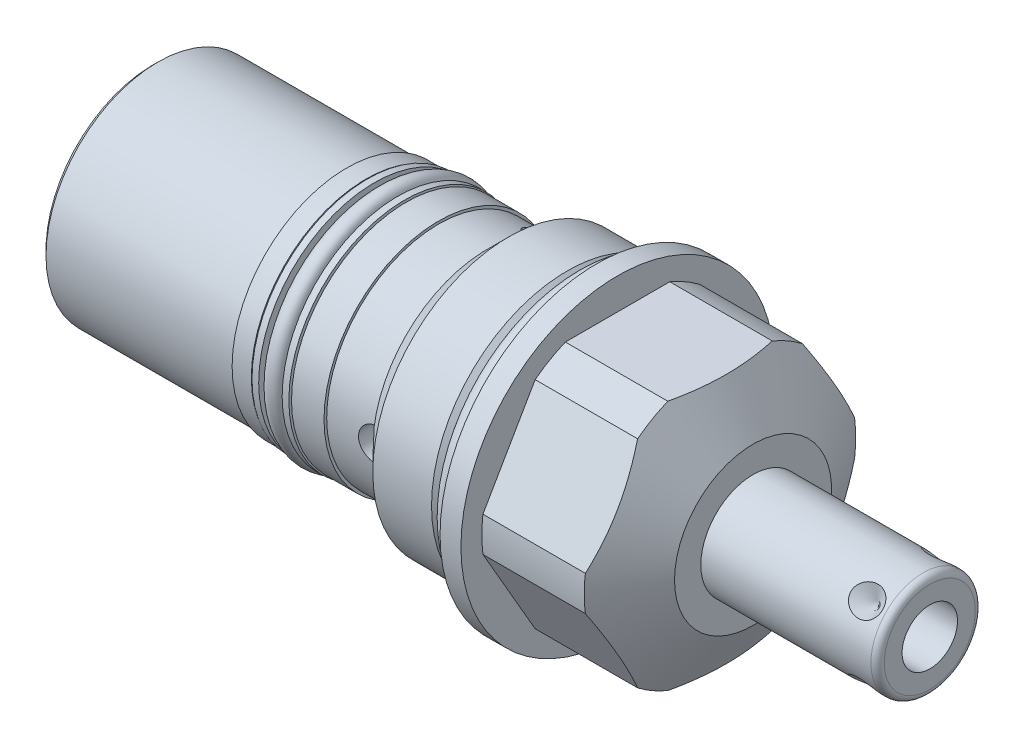
from build123d import *

# Parameters (mm, degrees)
SKETCH1_R           = 23.8125
EXTRUDE1_DEPTH      = 23.7744
EXTRUDE1_DEPTH_BACK = 67.4624
CUT_EXTRUDE1_REACH  = 69.462
SKETCH2_R           = 23.8125
SKETCH2_R_2         = 20.6375
CUT_EXTRUDE3_REACH  = 22.599
SKETCH5_R           = 23.8125
CUT_EXTRUDE5_START  = -15.576741
SKETCH7_R           = 23.8125
SKETCH7_R_2         = 20.6375
CUT_EXTRUDE5_DEPTH  = 15.576741
SKETCH12_W          = 6.1087
SKETCH12_H          = 2.032
SKETCH14_W          = 0.4064
SKETCH14_H          = 29.464
SKETCH14_H_2        = 7.4168
SKETCH15_R          = 1.4986
SKETCH16_W          = 2.1844
SKETCH16_H          = 1.016
SKETCH17_R          = 1.3081
CHAMFER1_SIZE       = 0.762
SKETCH23_R          = 2.5273
CUT_EXTRUDE7_DEPTH  = 24.8125
SKETCH25_R          = 3.1369
CUT_EXTRUDE8_DEPTH  = 0.762
SKETCH26_R          = 13.0302
EXTRUDE2_DEPTH      = 0.508
SKETCH28_R          = 3.1369
CUT_EXTRUDE9_DEPTH  = 0.508
CIRPATTERN2_COUNT   = 3
CIRPATTERN3_COUNT   = 4


with BuildPart() as part:
    # Sketch1 → Extrude1 (new body, two sides)
    with BuildSketch(Plane(origin=(0, 0, 0), x_dir=(0, 0, -1), z_dir=(1, 0, 0))) as extrude1_sk:
        Circle(SKETCH1_R)
    extrude(amount=EXTRUDE1_DEPTH)
    extrude(extrude1_sk.sketch, amount=-EXTRUDE1_DEPTH_BACK)

    # Sketch2 → Cut-Extrude1 (cut, up to next)
    with BuildSketch(Plane(origin=(0, 0, 0), x_dir=(0, 0, -1), z_dir=(1, 0, 0)), mode=Mode.PRIVATE) as cut_extrude1_sk1:
        Circle(SKETCH2_R)
        Circle(SKETCH2_R_2, mode=Mode.SUBTRACT)
    cut_extrude1_tool1 = extrude(cut_extrude1_sk1.sketch, amount=-CUT_EXTRUDE1_REACH, mode=Mode.PRIVATE) & part.part
    add(cut_extrude1_tool1.solids().sort_by_distance((0, 0, 23.138981))[0], mode=Mode.SUBTRACT)

    # Sketch3 → Cut-Revolve1 (revolve, cut)
    with BuildSketch(Plane.XY, mode=Mode.PRIVATE) as cut_revolve1_sk:
        Polygon((16.918654229, 23.8125), (23.7744, 11.938), (23.7744, 23.8125), align=None)
    revolve(cut_revolve1_sk.sketch.rotate(Axis((-8.14577342, 0, 0), (1, 0, 0)), 270), axis=Axis((-8.14577342, 0, 0), (1, 0, 0)), mode=Mode.SUBTRACT)  # turned: the seam where the file's is

    # Cut-Extrude3: up to this cone (the profile starts inside it)
    cut_extrude3_end = Plane(origin=(3.175, 0, 0), z_dir=(-1, 0, 0)).offset(-27.491806514) * Cone(1.732e-06, 170.10127155, 98.208013919, align=(Align.CENTER, Align.CENTER, Align.MIN), mode=Mode.PRIVATE)
    # Sketch5 → Cut-Extrude3 (cut, up to the surface)
    with BuildSketch(Plane.ZY.offset(-3.175), mode=Mode.PRIVATE) as cut_extrude3_sk1:
        with Locations(Location((0, 0, 0), (0, 0, 180))):  # turned: the seam where the file's is
            Circle(SKETCH5_R)
        Polygon((-10.998522628, 19.05), (10.998522628, 19.05), (21.997045256, 0), (10.998522628, -19.05), (-10.998522628, -19.05), (-21.997045256, 0), align=None, mode=Mode.SUBTRACT)
    cut_extrude3_tool1 = extrude(cut_extrude3_sk1.sketch, amount=-CUT_EXTRUDE3_REACH, mode=Mode.PRIVATE) & cut_extrude3_end
    add(cut_extrude3_tool1.solids().sort_by_distance((3.175, 0, 23.138981))[0], mode=Mode.SUBTRACT)

    # Sketch7 → Cut-Extrude5 (cut)
    with BuildSketch(Plane.ZY.offset(-3.175).offset(CUT_EXTRUDE5_START)):
        with Locations(Location((0, 0, 0), (0, 0, 180))):  # turned: the seam where the file's is
            Circle(SKETCH7_R)
        with Locations(Location((0, 0, 0), (0, 0, 180))):  # turned: the seam where the file's is
            Circle(SKETCH7_R_2, mode=Mode.SUBTRACT)
    extrude(amount=CUT_EXTRUDE5_DEPTH, mode=Mode.SUBTRACT)

    # Sketch9 → Cut-Revolve3 (revolve, cut)
    with BuildSketch(Plane.XY, mode=Mode.PRIVATE) as cut_revolve3_sk:
        Polygon((0, 20.6375), (0, 19.1389), (-2.9718, 19.1389), (-4.4704, 20.6375), align=None)
    revolve(cut_revolve3_sk.sketch.rotate(Axis((-4.4205525, 0, 0), (1, 0, 0)), 90), axis=Axis((-4.4205525, 0, 0), (1, 0, 0)), mode=Mode.SUBTRACT)  # turned: the seam where the file's is

    # Sketch10 → Cut-Revolve4 (revolve, cut)
    with BuildSketch(Plane.XY, mode=Mode.PRIVATE) as cut_revolve4_sk:
        Polygon((-13.3985, 20.6375), (-16.6116, 17.4244), (-67.4624, 17.4244), (-67.4624, 20.6375), align=None)
    revolve(cut_revolve4_sk.sketch.rotate(Axis((-55.9469925, 0, 0), (1, 0, 0)), 90), axis=Axis((-55.9469925, 0, 0), (1, 0, 0)), mode=Mode.SUBTRACT)  # turned: the seam where the file's is

    # Sketch12 → Cut-Revolve6 (revolve, cut)
    with BuildSketch(Plane.XY, mode=Mode.PRIVATE) as cut_revolve6_sk:
        with Locations((-32.02305, 16.4084)):
            Rectangle(SKETCH12_W, SKETCH12_H)
    revolve(cut_revolve6_sk.sketch.rotate(Axis((-31.750635, 0, 0), (1, 0, 0)), 90), axis=Axis((-31.750635, 0, 0), (1, 0, 0)), mode=Mode.SUBTRACT)  # turned: the seam where the file's is

    # Sketch14 → Cut-Revolve8 (revolve, cut)
    with BuildSketch(Plane(origin=(0, 0, 0), x_dir=(0, -1, 0), z_dir=(0, 0, 1)), mode=Mode.PRIVATE) as cut_revolve8_sk:
        with Locations((17.2212, -52.7304)):
            Rectangle(SKETCH14_W, SKETCH14_H)
        with Locations((17.2212, -20.32)):
            Rectangle(SKETCH14_W, SKETCH14_H_2)
    revolve(cut_revolve8_sk.sketch.rotate(Axis((-55.86603, 0, 0), (1, 0, 0)), 270), axis=Axis((-55.86603, 0, 0), (1, 0, 0)), mode=Mode.SUBTRACT)  # turned: the seam where the file's is

    # Sketch16 → Revolve2 (revolve)
    with BuildSketch(Plane(origin=(0, 0, 0), x_dir=(0, -1, 0), z_dir=(0, 0, 1)), mode=Mode.PRIVATE) as revolve2_sk:
        with Locations((16.4846, -29.7307)):
            Rectangle(SKETCH16_W, SKETCH16_H)
        with Locations((16.4846, -34.3154)):
            Rectangle(SKETCH16_W, SKETCH16_H)
    revolve(revolve2_sk.sketch.rotate(Axis((-31.471235, 0, 0), (1, 0, 0)), 270), axis=Axis((-31.471235, 0, 0), (1, 0, 0)))  # turned: the seam where the file's is

    # S2D0001 → Revolve4 (revolve)
    with BuildSketch(Plane(origin=(0, 0, 0), x_dir=(0, -1, 0), z_dir=(0, 0, 1)), mode=Mode.PRIVATE) as revolve4_sk:
        with BuildLine():
            Line((0, 23.7744), (-7.9375, 23.7744))
            Line((-7.9375, 23.7744), (-7.9375, 49.6316))
            ThreePointArc((-7.9375, 49.6316), (-7.63992049, 50.35002049), (-6.9215, 50.6476))
            Line((-6.9215, 50.6476), (0, 50.6476))
            Line((0, 50.6476), (0, 23.7744))
        make_face()
    revolve(revolve4_sk.sketch.rotate(Axis((7.265766347, 0, 0), (1, 0, 0)), 90), axis=Axis((7.265766347, 0, 0), (1, 0, 0)))  # turned: the seam where the file's is

    # Sketch19 → Cut-Revolve9 (revolve, cut)
    with BuildSketch(Plane(origin=(36.322, -2.8067, 0), x_dir=(0, -1, 0), z_dir=(0, 0, 1)), mode=Mode.PRIVATE) as cut_revolve9_sk:
        Polygon((1.4097, 14.3256), (1.4097, -0.9144), (-2.8067, -3.447868714), (-2.8067, 14.3256), align=None)
    revolve(cut_revolve9_sk.sketch.rotate(Axis((17.699325537, 0, 0), (1, 0, 0)), 270), axis=Axis((17.699325537, 0, 0), (1, 0, 0)), mode=Mode.SUBTRACT)  # turned: the seam where the file's is

    # S2D0002 → Cut-Revolve10 (revolve, cut)
    with BuildSketch(Plane(origin=(32.3596, -3.928862053, -3.928862053), x_dir=(1, 0, 0), z_dir=(0, 0.707106781, -0.707106781)), mode=Mode.PRIVATE) as cut_revolve10_sk:
        Polygon((14.3256, 2.38125), (16.7386, 2.38125), (14.3256, -0.03175), align=None)
    cut_revolve10 = revolve(cut_revolve10_sk.sketch.rotate(Axis((46.6852, -1.549290214, -1.549290214), (0, -0.707106781, -0.707106781)), 270), axis=Axis((46.6852, -1.549290214, -1.549290214), (0, -0.707106781, -0.707106781)), mode=Mode.SUBTRACT)  # turned: the seam where the file's is

    # Chamfer1
    chamfer1_edges = [part.edges().sort_by_distance(p)[0] for p in [
        (-67.4624, 0, -17.018),
    ]]
    chamfer(chamfer1_edges, length=CHAMFER1_SIZE)

    # Sketch23 → Cut-Extrude7 (cut, through all)
    with BuildSketch(Plane.XY):
        with Locations(Location((-16.6624, 0, 0), (0, 0, 180))):  # turned: the seam where the file's is
            Circle(SKETCH23_R)
    cut_extrude7 = extrude(amount=CUT_EXTRUDE7_DEPTH, mode=Mode.SUBTRACT)

    # Sketch25 → Cut-Extrude8 (cut)
    with BuildSketch(Plane.ZY.offset(67.4624)):
        Circle(SKETCH25_R)
    extrude(amount=-CUT_EXTRUDE8_DEPTH, mode=Mode.SUBTRACT)

    # Sketch26 → Extrude2 (add)
    with BuildSketch(Plane.ZY.offset(67.4624)):
        with Locations(Location((0, 0, 0), (0, 0, 180))):  # turned: the seam where the file's is
            Circle(SKETCH26_R)
    extrude(amount=EXTRUDE2_DEPTH)

    # Sketch28 → Cut-Extrude9 (cut)
    with BuildSketch(Plane.ZY.offset(67.9704)):
        Circle(SKETCH28_R)
    extrude(amount=-CUT_EXTRUDE9_DEPTH, mode=Mode.SUBTRACT)

    # CirPattern2: Cut-Extrude7 ×3 about axis
    cirpattern2_axis = Axis((7.265766347, 0, 0), (-1, 0, 0))
    for i in range(1, CIRPATTERN2_COUNT):
        add(cut_extrude7.rotate(cirpattern2_axis, i * 360 / CIRPATTERN2_COUNT), mode=Mode.SUBTRACT)

    # CirPattern3: Cut-Revolve10 ×4 about axis
    cirpattern3_axis = Axis((7.265766347, 0, 0), (-1, 0, 0))
    for i in range(1, CIRPATTERN3_COUNT):
        add(cut_revolve10.rotate(cirpattern3_axis, i * 360 / CIRPATTERN3_COUNT), mode=Mode.SUBTRACT)


with BuildPart() as body_2:
    # Sketch15 → Revolve1 (revolve)
    with BuildSketch(Plane(origin=(0, 0, 0), x_dir=(0, -1, 0), z_dir=(0, 0, 1)), mode=Mode.PRIVATE) as revolve1_sk:
        with Locations((20.6375, -1.4986)):
            Circle(SKETCH15_R)
    revolve(revolve1_sk.sketch.rotate(Axis((-3.09372, 0, 0), (1, 0, 0)), 270), axis=Axis((-3.09372, 0, 0), (1, 0, 0)))  # turned: the seam where the file's is


with BuildPart() as body_3:
    # Sketch17 → Revolve3 (revolve)
    with BuildSketch(Plane(origin=(0, 0, 0), x_dir=(0, -1, 0), z_dir=(0, 0, 1)), mode=Mode.PRIVATE) as revolve3_sk:
        with Locations((16.7005, -32.02305)):
            Circle(SKETCH17_R)
    revolve(revolve3_sk.sketch.rotate(Axis((-31.750635, 0, 0), (1, 0, 0)), 270), axis=Axis((-31.750635, 0, 0), (1, 0, 0)))  # turned: the seam where the file's is


solid = Compound([part.part, body_2.part, body_3.part])
